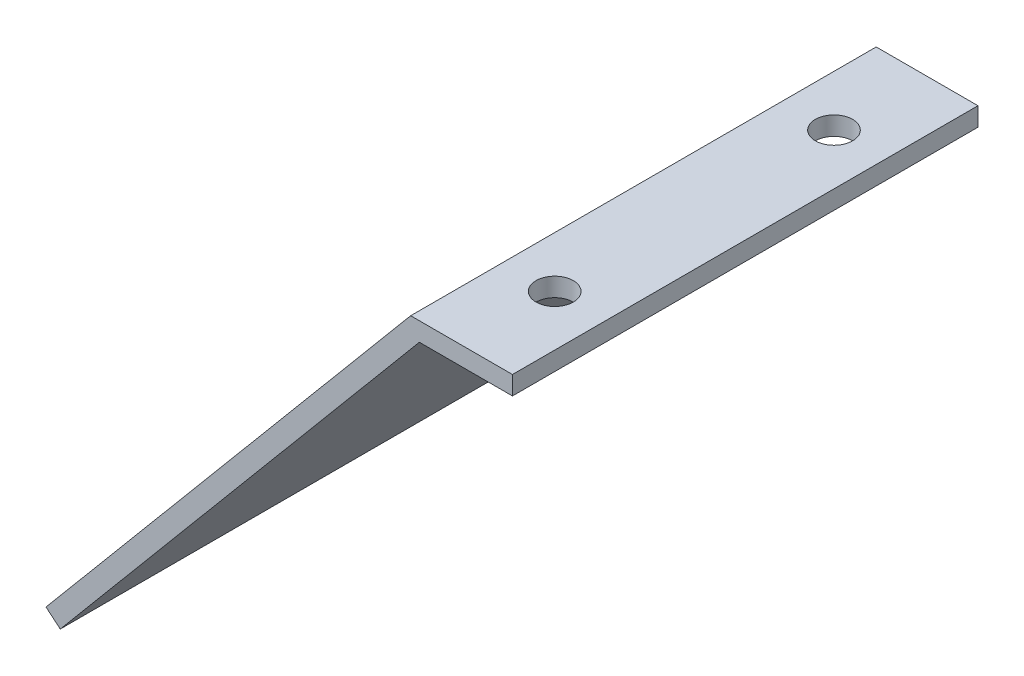
from build123d import *

# Parameters (mm, degrees)
BOSS_EXTRUDE1_DEPTH = 50
CUT_EXTRUDE1_REACH  = 49.963
SKETCH2_R           = 2


with BuildPart() as part:
    # Sketch1 → Boss-Extrude1 (new body)
    with BuildSketch(Plane.XY):
        Polygon((0, 0), (-10, 0), (-48.567256581, -45.962666587), (-50.099345467, -44.677091368), (-10.932615316, 2), (0, 2), align=None)
    extrude(amount=BOSS_EXTRUDE1_DEPTH)

    # Sketch2 → Cut-Extrude1 (cut, up to next)
    with BuildSketch(Plane(origin=(0, 2, 0), x_dir=(1, 0, 0), z_dir=(0, 1, 0)), mode=Mode.PRIVATE) as cut_extrude1_sk1:
        with Locations((-5.466307658, -10)):
            Circle(SKETCH2_R)
    cut_extrude1_tool1 = extrude(cut_extrude1_sk1.sketch, amount=-CUT_EXTRUDE1_REACH, mode=Mode.PRIVATE) & part.part
    add(cut_extrude1_tool1.solids().sort_by_distance((-5.466308, 2, 10))[0], mode=Mode.SUBTRACT)
    # Sketch2 → Cut-Extrude1 (cut, up to next)
    with BuildSketch(Plane(origin=(0, 2, 0), x_dir=(1, 0, 0), z_dir=(0, 1, 0)), mode=Mode.PRIVATE) as cut_extrude1_sk2:
        with Locations((-5.466307658, -40)):
            Circle(SKETCH2_R)
    cut_extrude1_tool2 = extrude(cut_extrude1_sk2.sketch, amount=-CUT_EXTRUDE1_REACH, mode=Mode.PRIVATE) & part.part
    add(cut_extrude1_tool2.solids().sort_by_distance((-5.466308, 2, 40))[0], mode=Mode.SUBTRACT)


solid = part.part
